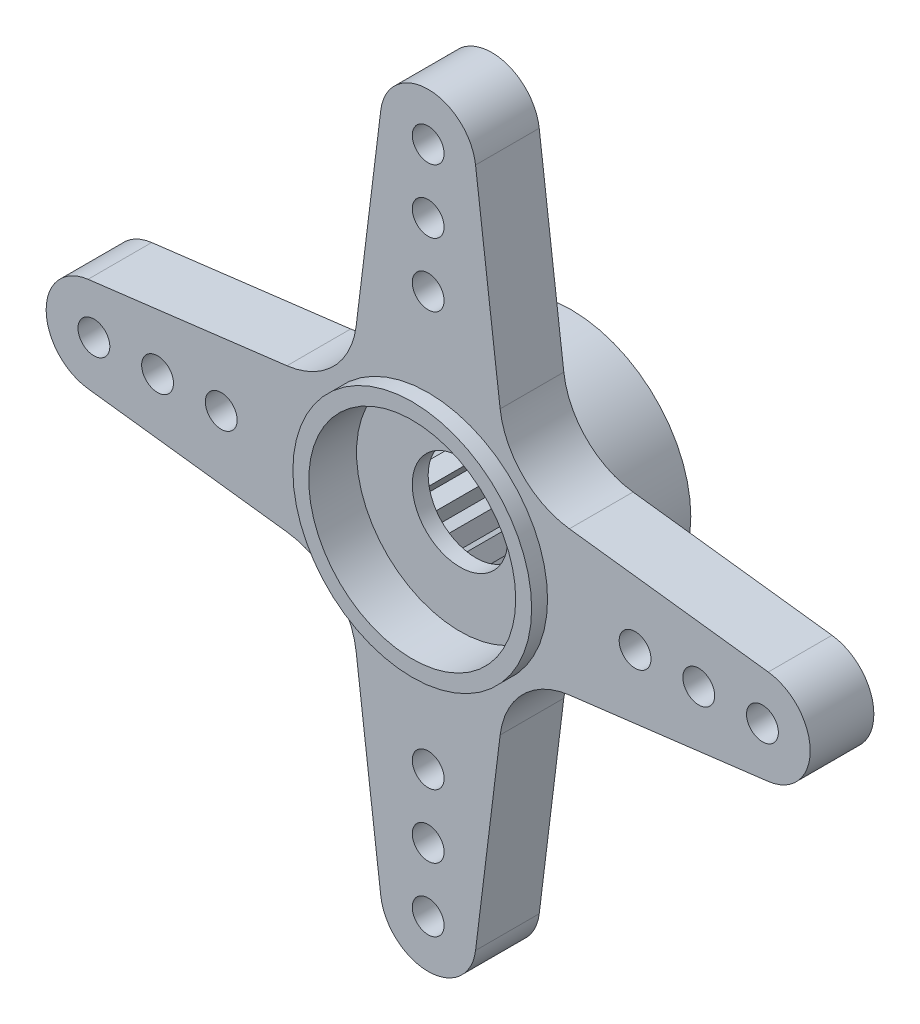
from build123d import *

# Parameters (mm, degrees)
ESQUISSE1_R                  = 0.5
BASE_EXTRUSION_DEPTH         = 1
ESQUISSE2_R                  = 3.75
BOSS_EXTRU_1_DEPTH           = 0.5
ESQUISSE3_R                  = 3.75
BOSS_EXTRU_2_DEPTH           = 2.5
ESQUISSE4_R                  = 3.25
ENL_V_MAT_EXTRU_1_DEPTH      = 1.5
ESQUISSE5_R                  = 1.5
ENL_V_MAT_EXTRU_2_DEPTH      = 4.5
ESQUISSE7_R                  = 2.2
ENL_V_MAT_EXTRU_4_DEPTH      = 3
DENTS_DEPTH                  = 3
R_P_TITION_CIRCULAIRE1_COUNT = 24


with BuildPart() as part:
    # Esquisse1 → Base-Extrusion (new body, symmetric)
    with BuildSketch(Plane.XY):
        with BuildLine():
            Line((1.488676655, 10.683961455), (2.260839574, 4.435364907))
            ThreePointArc((2.260839574, 4.435364907), (2.974200379, 2.974200379), (4.435364907, 2.260839574))
            Line((4.435364907, 2.260839574), (10.683961455, 1.488676655))
            ThreePointArc((10.683961455, 1.488676655), (12, 0), (10.683961455, -1.488676655))
            Line((10.683961455, -1.488676655), (4.435364907, -2.260839574))
            ThreePointArc((4.435364907, -2.260839574), (2.974200379, -2.974200379), (2.260839574, -4.435364907))
            Line((2.260839574, -4.435364907), (1.488676655, -10.683961455))
            ThreePointArc((1.488676655, -10.683961455), (0, -12), (-1.488676655, -10.683961455))
            Line((-1.488676655, -10.683961455), (-2.260839574, -4.435364907))
            ThreePointArc((-2.260839574, -4.435364907), (-2.974200379, -2.974200379), (-4.435364907, -2.260839574))
            Line((-4.435364907, -2.260839574), (-10.683961455, -1.488676655))
            ThreePointArc((-10.683961455, -1.488676655), (-12, 0), (-10.683961455, 1.488676655))
            Line((-10.683961455, 1.488676655), (-4.435364907, 2.260839574))
            ThreePointArc((-4.435364907, 2.260839574), (-2.974200379, 2.974200379), (-2.260839574, 4.435364907))
            Line((-2.260839574, 4.435364907), (-1.488676655, 10.683961455))
            ThreePointArc((-1.488676655, 10.683961455), (0, 12), (1.488676655, 10.683961455))
        make_face()
        with Locations((10.5, 0)):
            Circle(ESQUISSE1_R, mode=Mode.SUBTRACT)
        with Locations((8.5, 0)):
            Circle(ESQUISSE1_R, mode=Mode.SUBTRACT)
        with Locations((6.5, 0)):
            Circle(ESQUISSE1_R, mode=Mode.SUBTRACT)
        with Locations((0, -10.5)):
            Circle(ESQUISSE1_R, mode=Mode.SUBTRACT)
        with Locations((0, -8.5)):
            Circle(ESQUISSE1_R, mode=Mode.SUBTRACT)
        with Locations((0, -6.5)):
            Circle(ESQUISSE1_R, mode=Mode.SUBTRACT)
        with Locations((0, 10.5)):
            Circle(ESQUISSE1_R, mode=Mode.SUBTRACT)
        with Locations((0, 8.5)):
            Circle(ESQUISSE1_R, mode=Mode.SUBTRACT)
        with Locations((0, 6.5)):
            Circle(ESQUISSE1_R, mode=Mode.SUBTRACT)
        with Locations((-10.5, 0)):
            Circle(ESQUISSE1_R, mode=Mode.SUBTRACT)
        with Locations((-8.5, 0)):
            Circle(ESQUISSE1_R, mode=Mode.SUBTRACT)
        with Locations((-6.5, 0)):
            Circle(ESQUISSE1_R, mode=Mode.SUBTRACT)
    extrude(amount=BASE_EXTRUSION_DEPTH, both=True)

    # Esquisse2 → Boss.-Extru.1 (add)
    with BuildSketch(Plane.XY.offset(1)):
        Circle(ESQUISSE2_R)
    extrude(amount=BOSS_EXTRU_1_DEPTH)

    # Esquisse3 → Boss.-Extru.2 (add)
    with BuildSketch(Plane(origin=(0, 0, -1), x_dir=(-1, 0, 0), z_dir=(0, 0, -1))):
        Circle(ESQUISSE3_R)
    extrude(amount=BOSS_EXTRU_2_DEPTH)

    # Esquisse4 → Enlèv. mat.-Extru.1 (cut)
    with BuildSketch(Plane.XY.offset(1.5)):
        Circle(ESQUISSE4_R)
    extrude(amount=-ENL_V_MAT_EXTRU_1_DEPTH, mode=Mode.SUBTRACT)

    # Esquisse5 → Enlèv. mat.-Extru.2 (cut, through all)
    with BuildSketch(Plane.XY):
        Circle(ESQUISSE5_R)
    extrude(amount=-ENL_V_MAT_EXTRU_2_DEPTH, mode=Mode.SUBTRACT)

    # Esquisse7 → Enlèv. mat.-Extru.4 (cut)
    with BuildSketch(Plane(origin=(0, 0, -3.5), x_dir=(-1, 0, 0), z_dir=(0, 0, -1))):
        Circle(ESQUISSE7_R)
    extrude(amount=-ENL_V_MAT_EXTRU_4_DEPTH, mode=Mode.SUBTRACT)

    # Esquisse6 → Dents (cut)
    with BuildSketch(Plane(origin=(0, 0, -3.5), x_dir=(-1, 0, 0), z_dir=(0, 0, -1))):
        with BuildLine():
            Line((0, 2.8), (0.288653169, 2.180981281))
            ThreePointArc((0.288653169, 2.180981281), (0, 2.2), (-0.288653169, 2.180981281))
            Line((-0.288653169, 2.180981281), (0, 2.8))
        make_face()
    dents = extrude(amount=-DENTS_DEPTH, mode=Mode.SUBTRACT)

    # Répétition circulaire1: Dents ×24 about axis
    r_p_tition_circulaire1_axis = Axis((0, 0, 0), (0, 0, 1))
    for i in range(1, R_P_TITION_CIRCULAIRE1_COUNT):
        add(dents.rotate(r_p_tition_circulaire1_axis, i * 360 / R_P_TITION_CIRCULAIRE1_COUNT), mode=Mode.SUBTRACT)


solid = part.part
